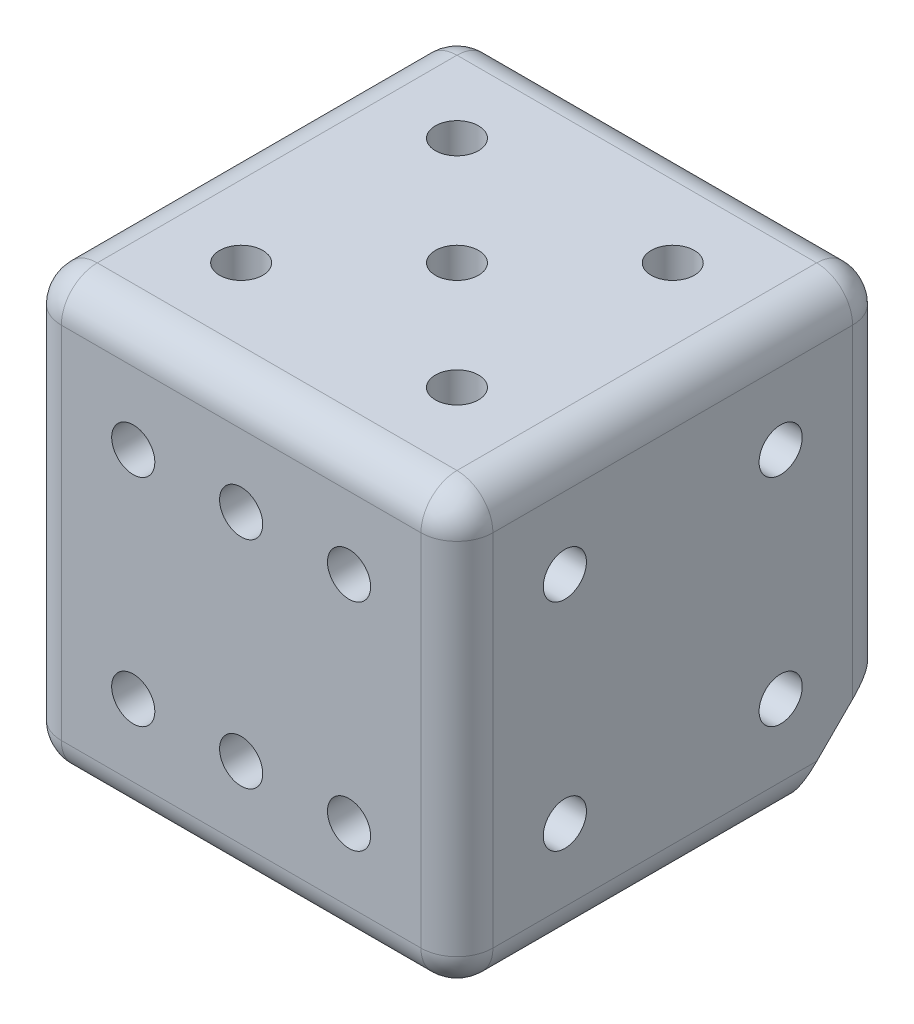
from build123d import *

# Parameters (mm, degrees)
SKETCH1_W                    = 30
SKETCH1_H                    = 30
BOSS_EXTRUDE1_DEPTH          = 30
F_3_0_3_DIAMETER_HOLE1_D     = 3
F_3_0_3_DIAMETER_HOLE1_DEPTH = 2.5
F_3_0_3_DIAMETER_HOLE1_TIP   = 0.901290929
F_3_0_3_DIAMETER_HOLE2_D     = 3
F_3_0_3_DIAMETER_HOLE2_DEPTH = 2.5
F_3_0_3_DIAMETER_HOLE2_TIP   = 0.901290929
F_3_0_3_DIAMETER_HOLE3_D     = 3
F_3_0_3_DIAMETER_HOLE3_DEPTH = 2.5
F_3_0_3_DIAMETER_HOLE3_TIP   = 0.901290929
F_3_0_3_DIAMETER_HOLE4_D     = 3
F_3_0_3_DIAMETER_HOLE4_DEPTH = 2.5
F_3_0_3_DIAMETER_HOLE4_TIP   = 0.901290929
F_3_0_3_DIAMETER_HOLE5_D     = 3
F_3_0_3_DIAMETER_HOLE5_DEPTH = 2.5
F_3_0_3_DIAMETER_HOLE5_TIP   = 0.901290929
F_3_0_3_DIAMETER_HOLE6_D     = 3
F_3_0_3_DIAMETER_HOLE6_DEPTH = 2.5
F_3_0_3_DIAMETER_HOLE6_TIP   = 0.901290929
SKETCH14_W                   = 17.836209409
SKETCH14_H                   = 14.772604036
CUT_EXTRUDE1_DEPTH           = 5.320508076
FILLET1_R                    = 2.5


with BuildPart() as part:
    # Sketch1 → Boss-Extrude1 (new body)
    with BuildSketch(Plane(origin=(0, 0, 0), x_dir=(1, 0, 0), z_dir=(0, 1, 0))):
        with Locations((15, 15)):
            Rectangle(SKETCH1_W, SKETCH1_H)
    extrude(amount=BOSS_EXTRUDE1_DEPTH)

    # Ø3.0 (3) Diameter Hole1
    with Locations(Plane(origin=(7.5, 22.5, 0), x_dir=(1, 0, 0), z_dir=(0, 0, 1))):
        with Locations((0, 0), (7.5, 0), (15, 0), (15, -15), (7.5, -15), (0, -15)):
            Hole(F_3_0_3_DIAMETER_HOLE1_D / 2, depth=F_3_0_3_DIAMETER_HOLE1_DEPTH)
            with Locations((0, 0, -(F_3_0_3_DIAMETER_HOLE1_DEPTH + F_3_0_3_DIAMETER_HOLE1_TIP / 2))):  # 118° drill point
                Cone(0, F_3_0_3_DIAMETER_HOLE1_D / 2, F_3_0_3_DIAMETER_HOLE1_TIP, mode=Mode.SUBTRACT)

    # Ø3.0 (3) Diameter Hole2
    with Locations(Plane(origin=(7.5, 30, -22.5), x_dir=(0, 0, 1), z_dir=(0, 1, 0))):
        with Locations((0, 0), (7.5, 7.5), (0, 15), (15, 15), (15, 0)):
            Hole(F_3_0_3_DIAMETER_HOLE2_D / 2, depth=F_3_0_3_DIAMETER_HOLE2_DEPTH)
            with Locations((0, 0, -(F_3_0_3_DIAMETER_HOLE2_DEPTH + F_3_0_3_DIAMETER_HOLE2_TIP / 2))):  # 118° drill point
                Cone(0, F_3_0_3_DIAMETER_HOLE2_D / 2, F_3_0_3_DIAMETER_HOLE2_TIP, mode=Mode.SUBTRACT)

    # Ø3.0 (3) Diameter Hole3
    with Locations(Plane(origin=(15, 15, -30), x_dir=(-1, 0, 0), z_dir=(0, 0, -1))):
        with Locations((0, 0)):
            Hole(F_3_0_3_DIAMETER_HOLE3_D / 2, depth=F_3_0_3_DIAMETER_HOLE3_DEPTH)
            with Locations((0, 0, -(F_3_0_3_DIAMETER_HOLE3_DEPTH + F_3_0_3_DIAMETER_HOLE3_TIP / 2))):  # 118° drill point
                Cone(0, F_3_0_3_DIAMETER_HOLE3_D / 2, F_3_0_3_DIAMETER_HOLE3_TIP, mode=Mode.SUBTRACT)

    # Ø3.0 (3) Diameter Hole4
    with Locations(Plane(origin=(7.5, 0, -7.5), x_dir=(0, 0, -1), z_dir=(0, -1, 0))):
        with Locations((0, 0), (15, 15)):
            Hole(F_3_0_3_DIAMETER_HOLE4_D / 2, depth=F_3_0_3_DIAMETER_HOLE4_DEPTH)
            with Locations((0, 0, -(F_3_0_3_DIAMETER_HOLE4_DEPTH + F_3_0_3_DIAMETER_HOLE4_TIP / 2))):  # 118° drill point
                Cone(0, F_3_0_3_DIAMETER_HOLE4_D / 2, F_3_0_3_DIAMETER_HOLE4_TIP, mode=Mode.SUBTRACT)

    # Ø3.0 (3) Diameter Hole5
    with Locations(Plane(origin=(30, 7.5, -7.5), x_dir=(0, 0, 1), z_dir=(1, 0, 0))):
        with Locations((0, 0), (-15, 0), (-15, -15), (0, -15)):
            Hole(F_3_0_3_DIAMETER_HOLE5_D / 2, depth=F_3_0_3_DIAMETER_HOLE5_DEPTH)
            with Locations((0, 0, -(F_3_0_3_DIAMETER_HOLE5_DEPTH + F_3_0_3_DIAMETER_HOLE5_TIP / 2))):  # 118° drill point
                Cone(0, F_3_0_3_DIAMETER_HOLE5_D / 2, F_3_0_3_DIAMETER_HOLE5_TIP, mode=Mode.SUBTRACT)

    # Ø3.0 (3) Diameter Hole6
    with Locations(Plane(origin=(0, 22.5, -7.5), x_dir=(0, 0, -1), z_dir=(-1, 0, 0))):
        with Locations((0, 0), (7.5, 7.5), (15, 15)):
            Hole(F_3_0_3_DIAMETER_HOLE6_D / 2, depth=F_3_0_3_DIAMETER_HOLE6_DEPTH)
            with Locations((0, 0, -(F_3_0_3_DIAMETER_HOLE6_DEPTH + F_3_0_3_DIAMETER_HOLE6_TIP / 2))):  # 118° drill point
                Cone(0, F_3_0_3_DIAMETER_HOLE6_D / 2, F_3_0_3_DIAMETER_HOLE6_TIP, mode=Mode.SUBTRACT)

    # Sketch14 → Cut-Extrude1 (cut, through all)
    with BuildSketch(Plane(origin=(17.505553499, -17.505553499, -17.505553499), x_dir=(0.816496581, 0.40824829, 0.40824829), z_dir=(-0.577350269, 0.577350269, 0.577350269))):
        with Locations((11.862983406, 20.967424405)):
            Rectangle(SKETCH14_W, SKETCH14_H)
    extrude(amount=-CUT_EXTRUDE1_DEPTH, mode=Mode.SUBTRACT)

    # Fillet1
    fillet1_edges = [part.edges().sort_by_distance(p)[0] for p in [
        (30, 30, -15),
        (11.258330249, 0, -30),
        (15, 30, -30),
        (0, 30, -15),
        (30, 0, -11.258330249),
        (15, 0, 0),
        (0, 0, -15),
        (15, 30, 0),
        (0, 15, -30),
        (30, 18.741669751, -30),
        (30, 15, 0),
        (0, 15, 0),
    ]]
    fillet(fillet1_edges, radius=FILLET1_R)


solid = part.part
